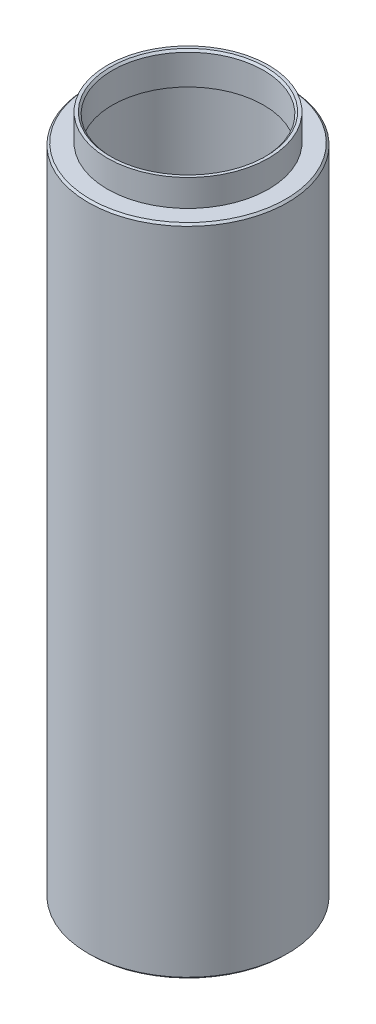
from build123d import *


with BuildPart() as part:
    # Sketch1 → Revolve1 (revolve)
    with BuildSketch(Plane.XY):
        Polygon((12.7, 0), (12.7, 98.552), (13.208, 98.552), (13.208, 99.2), (11.557, 99.2), (11.557, 103.8), (11.857, 104.1), (12.319, 104.1), (12.319, 100), (14.95, 100), (15.25, 99.7), (15.25, 0.3), (14.95, 0), align=None)
    revolve(axis=Axis((0, 0, 0), (0, 1, 0)))


solid = part.part
